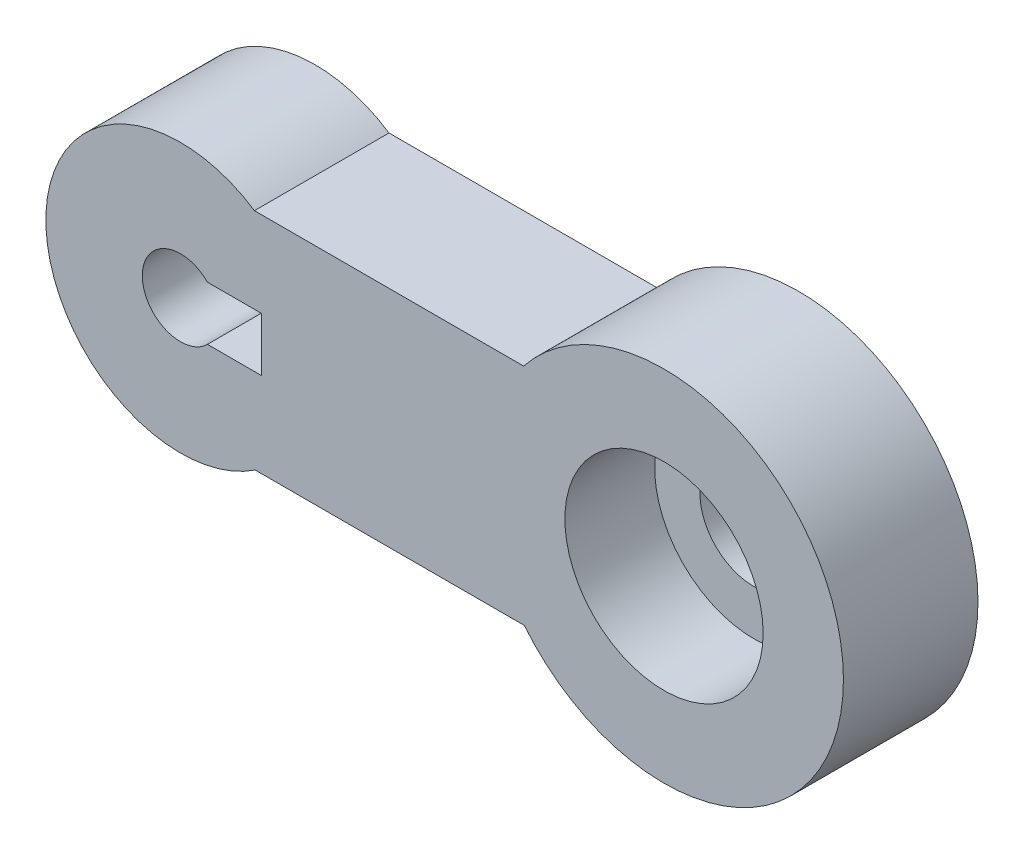
from build123d import *

# Parameters (mm, degrees)
SKETCH1_R           = 4.25
BOSS_EXTRUDE1_DEPTH = 15
SKETCH2_R           = 11.05
CUT_EXTRUDE1_DEPTH  = 10
SKETCH3_R           = 6
CUT_EXTRUDE2_DEPTH  = 10
CUT_EXTRUDE5_DEPTH  = 15


with BuildPart() as part:
    # Sketch1 → Boss-Extrude1 (new body)
    with BuildSketch(Plane.XY):
        with BuildLine():
            Line((-16.865782324, -15.62917697), (13.134217676, -15.62917697))
            ThreePointArc((13.134217676, -15.62917697), (48.706833622, -3.016216146), (13.054918576, 9.37082303))
            Line((13.054918576, 9.37082303), (-16.945081424, 9.37082303))
            ThreePointArc((-16.945081424, 9.37082303), (-40.196781878, -3.203056293), (-16.865782324, -15.62917697))
        make_face()
        with Locations((-25.196857337, -3.155477073)):
            Circle(SKETCH1_R, mode=Mode.SUBTRACT)
    extrude(amount=BOSS_EXTRUDE1_DEPTH)

    # Sketch2 → Cut-Extrude1 (cut)
    with BuildSketch(Plane.XY.offset(15)):
        with Locations((28.706934234, -3.079655107)):
            Circle(SKETCH2_R)
    extrude(amount=-CUT_EXTRUDE1_DEPTH, mode=Mode.SUBTRACT)

    # Sketch3 → Cut-Extrude2 (cut)
    with BuildSketch(Plane.XY.offset(5)):
        with Locations((28.706934234, -3.079655107)):
            Circle(SKETCH3_R)
    extrude(amount=-CUT_EXTRUDE2_DEPTH, mode=Mode.SUBTRACT)

    # Sketch5 → Cut-Extrude5 (cut)
    with BuildSketch(Plane.XY.offset(15)):
        with BuildLine():
            Line((-16.186458693, -0.155477073), (-22.186458693, -0.155477073))
            ThreePointArc((-22.186458693, -0.155477073), (-29.446857337, -3.155477073), (-22.186458693, -6.155477073))
            Line((-22.186458693, -6.155477073), (-16.186458693, -6.155477073))
            Line((-16.186458693, -6.155477073), (-16.186458693, -0.155477073))
        make_face()
    extrude(amount=-CUT_EXTRUDE5_DEPTH, mode=Mode.SUBTRACT)


solid = part.part
